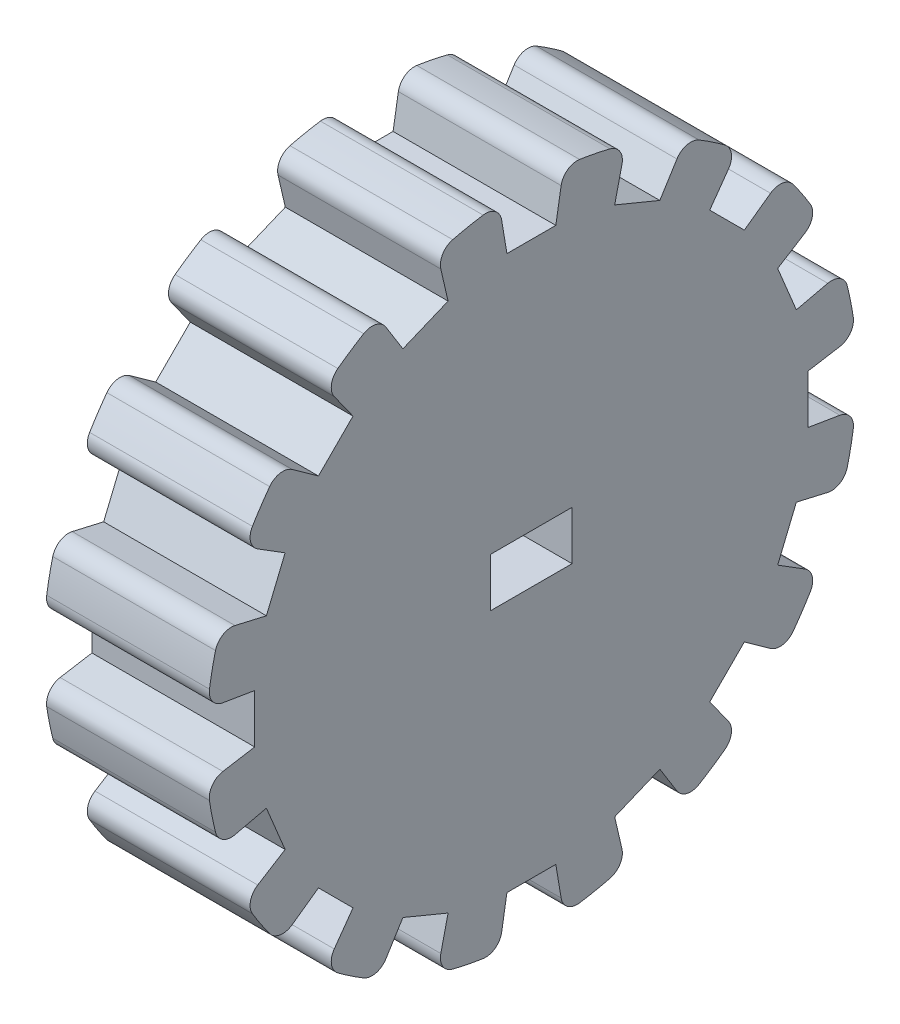
from build123d import *

# Parameters (mm, degrees)
SKETCH4_W                = 5
SKETCH4_H                = 3
CUT_EXTRUDE2_DEPTH       = 10
CUT_EXTRUDE3_DEPTH       = 10
FILLET1_R                = 1
CIRPATTERN1_COUNT        = 16
FILLET1_OF_CIRPATTERN1_R = 1


with BuildPart() as part:
    # Sketch1 → Revolve1 (revolve)
    with BuildSketch(Plane.XY):
        Polygon((0, 0), (-10, 0), (-10, 5), (-10, 10), (-10, 20), (0, 20), (0, 5), align=None)
    revolve(axis=Axis((0, 0, 0), (-1, 0, 0)))

    # Sketch4 → Cut-Extrude2 (cut)
    with BuildSketch(Plane.ZY.offset(10)):
        Rectangle(SKETCH4_W, SKETCH4_H)
    extrude(amount=-CUT_EXTRUDE2_DEPTH, mode=Mode.SUBTRACT)

    # Sketch5 → Cut-Extrude3 (cut)
    with BuildSketch(Plane(origin=(0, 0, 0), x_dir=(0, 0, -1), z_dir=(1, 0, 0))):
        Polygon((-2.502016427, 23), (2.502016427, 23), (1.501758676, 17), (-1.501758676, 17), align=None)
    cut_extrude3 = extrude(amount=-CUT_EXTRUDE3_DEPTH, mode=Mode.SUBTRACT)

    # Fillet1
    fillet1_edges = [part.edges().sort_by_distance(p)[0] for p in [
        (-5, 19.90120888, -1.985418121),
        (-5, 19.90120888, 1.985418121),
    ]]
    fillet(fillet1_edges, radius=FILLET1_R)

    # CirPattern1: Cut-Extrude3 ×16 about axis
    cirpattern1_axis = Axis((0, 0, 0), (1, 0, 0))
    for i in range(1, CIRPATTERN1_COUNT):
        add(cut_extrude3.rotate(cirpattern1_axis, i * 360 / CIRPATTERN1_COUNT), mode=Mode.SUBTRACT)

    # Fillet1 of CirPattern1
    fillet1_of_cirpattern1_edges = [part.edges().sort_by_distance(p)[0] for p in [
        (-5, 19.146106178, 5.781575757),
        (-5, 17.626532935, 9.450150088),
        (-5, 15.47618237, 12.668377136),
        (-5, 12.668377136, 15.47618237),
        (-5, 9.450150088, 17.626532935),
        (-5, 5.781575757, 19.146106178),
        (-5, 1.985418121, 19.90120888),
        (-5, -1.985418121, 19.90120888),
        (-5, -5.781575757, 19.146106178),
        (-5, -9.450150088, 17.626532935),
        (-5, -12.668377136, 15.47618237),
        (-5, -15.47618237, 12.668377136),
        (-5, -17.626532935, 9.450150088),
        (-5, -19.146106178, 5.781575757),
        (-5, -19.90120888, 1.985418121),
        (-5, -19.90120888, -1.985418121),
        (-5, -19.146106178, -5.781575757),
        (-5, -17.626532935, -9.450150088),
        (-5, -15.47618237, -12.668377136),
        (-5, -12.668377136, -15.47618237),
        (-5, -9.450150088, -17.626532935),
        (-5, -5.781575757, -19.146106178),
        (-5, -1.985418121, -19.90120888),
        (-5, 1.985418121, -19.90120888),
        (-5, 5.781575757, -19.146106178),
        (-5, 9.450150088, -17.626532935),
        (-5, 12.668377136, -15.47618237),
        (-5, 15.47618237, -12.668377136),
        (-5, 17.626532935, -9.450150088),
        (-5, 19.146106178, -5.781575757),
    ]]
    fillet(fillet1_of_cirpattern1_edges, radius=FILLET1_OF_CIRPATTERN1_R)


solid = part.part
